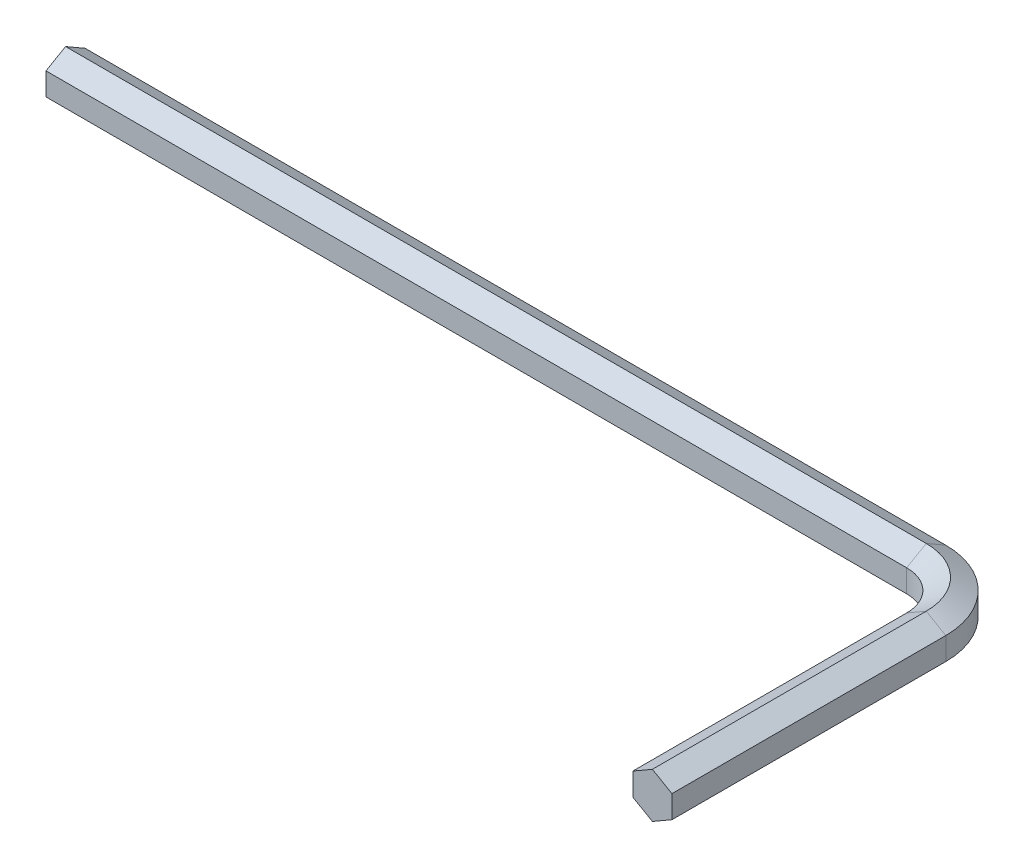
from build123d import *


with BuildPart() as part:
    # Sweep1: sweep along a path in Sketch2
    with BuildLine(Plane(origin=(0, 0, 0), x_dir=(1, 0, 0), z_dir=(0, 1, 0))) as sweep1_path:
        Line((0, 0), (0, 14))
        ThreePointArc((0, 14), (-0.878679656, 16.121320344), (-3, 17))
        Line((-3, 17), (-47, 17))
    # Sketch1 → Sweep1 (sweep)
    with BuildSketch(Plane.XY):
        Polygon((0, 1.154700538), (-1, 0.577350269), (-1, -0.577350269), (0, -1.154700538), (1, -0.577350269), (1, 0.577350269), align=None)
    sweep(path=sweep1_path.line)


solid = part.part
